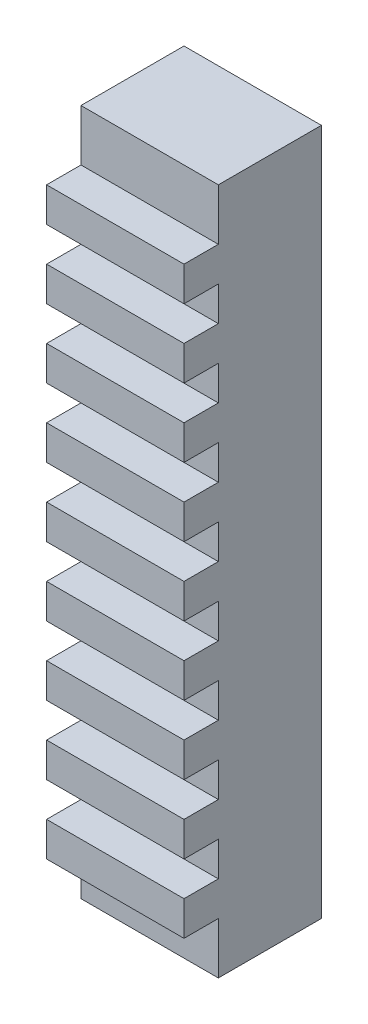
from build123d import *

# Parameters (mm, degrees)
SKETCH1_W           = 20
SKETCH1_H           = 100
BOSS_EXTRUDE1_DEPTH = 15
SKETCH2_W           = 20
SKETCH2_H           = 5
BOSS_EXTRUDE2_DEPTH = 5


with BuildPart() as part:
    # Sketch1 → Boss-Extrude1 (new body)
    with BuildSketch(Plane.XY):
        Rectangle(SKETCH1_W, SKETCH1_H)
    extrude(amount=BOSS_EXTRUDE1_DEPTH)

    # Sketch2 → Boss-Extrude2 (add)
    with BuildSketch(Plane.XY.offset(15)):
        Rectangle(SKETCH2_W, SKETCH2_H)
        with Locations((0, -10)):
            Rectangle(SKETCH2_W, SKETCH2_H)
        with Locations((0, -20)):
            Rectangle(SKETCH2_W, SKETCH2_H)
        with Locations((0, -30)):
            Rectangle(SKETCH2_W, SKETCH2_H)
        with Locations((0, -40)):
            Rectangle(SKETCH2_W, SKETCH2_H)
        with Locations((0, 10)):
            Rectangle(SKETCH2_W, SKETCH2_H)
        with Locations((0, 20)):
            Rectangle(SKETCH2_W, SKETCH2_H)
        with Locations((0, 30)):
            Rectangle(SKETCH2_W, SKETCH2_H)
        with Locations((0, 40)):
            Rectangle(SKETCH2_W, SKETCH2_H)
    extrude(amount=BOSS_EXTRUDE2_DEPTH)


solid = part.part
